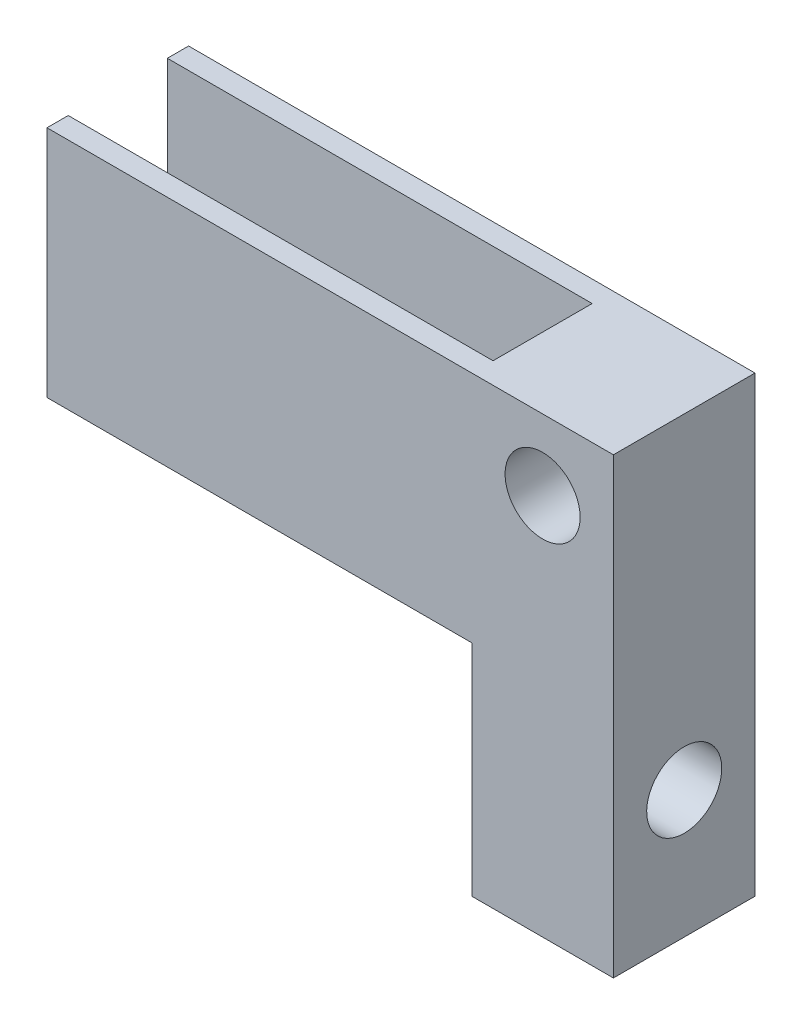
from build123d import *

# Parameters (mm, degrees)
SKETCH2_W           = 10
SKETCH2_H           = 50
BOSS_EXTRUDE1_DEPTH = 10
SKETCH6_R           = 2.65
CUT_EXTRUDE3_DEPTH  = 11
SKETCH7_R           = 2.35
SKETCH7_R_2         = 2.65
CUT_EXTRUDE4_DEPTH  = 11
SKETCH8_W           = 1.5
SKETCH8_H           = 21
BOSS_EXTRUDE2_DEPTH = 30
SKETCH9_W           = 52.99414334
SKETCH9_H           = 19.059793282
CUT_EXTRUDE5_DEPTH  = 11


with BuildPart() as part:
    # Sketch2 → Boss-Extrude1 (new body)
    with BuildSketch(Plane.XY):
        with Locations((5, 25)):
            Rectangle(SKETCH2_W, SKETCH2_H)
    extrude(amount=BOSS_EXTRUDE1_DEPTH)

    # Sketch6 → Cut-Extrude3 (cut, through all)
    with BuildSketch(Plane.XY.offset(10)):
        with Locations((5, 27)):
            Circle(SKETCH6_R)
    extrude(amount=-CUT_EXTRUDE3_DEPTH, mode=Mode.SUBTRACT)

    # Sketch7 → Cut-Extrude4 (cut, through all)
    with BuildSketch(Plane.ZY):
        with Locations((5, 41)):
            Circle(SKETCH7_R)
        with Locations((5, 9)):
            Circle(SKETCH7_R_2)
    extrude(amount=-CUT_EXTRUDE4_DEPTH, mode=Mode.SUBTRACT)

    # Sketch8 → Boss-Extrude2 (add)
    with BuildSketch(Plane.ZY):
        with Locations((9.25, 26)):
            Rectangle(SKETCH8_W, SKETCH8_H)
        with Locations((0.75, 26)):
            Rectangle(SKETCH8_W, SKETCH8_H)
    extrude(amount=BOSS_EXTRUDE2_DEPTH)

    # Sketch9 → Cut-Extrude5 (cut, through all)
    with BuildSketch(Plane.XY.offset(10)):
        with Locations((-7.642110933, 41.529896641)):
            Rectangle(SKETCH9_W, SKETCH9_H)
    extrude(amount=-CUT_EXTRUDE5_DEPTH, mode=Mode.SUBTRACT)


solid = part.part
